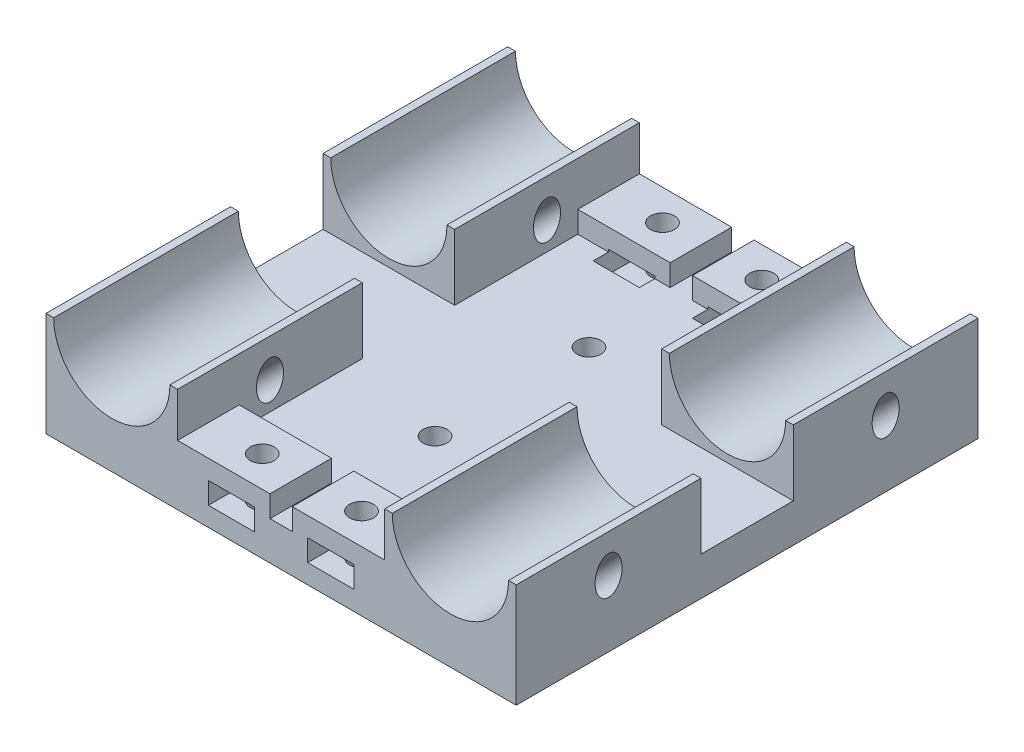
from build123d import *

# Parameters (mm, degrees)
SKETCH1_W               = 61.1
SKETCH1_H               = 60
BOSS_EXTRUDE1_DEPTH     = 5
BOSS_EXTRUDE2_DEPTH     = 24
MIRROR2_COPY_1_DEPTH    = 24
CUT_EXTRUDE1_START      = -47.739758236
SKETCH3_R               = 1.75
CUT_EXTRUDE1_DEPTH      = 54.785521216
MIRROR4_START           = -47.739758236
MIRROR4_COPY_1_SKETCH_R = 1.75
MIRROR4_COPY_1_DEPTH    = 54.785521216
MIRROR5_START           = -47.739758236
MIRROR5_COPY_1_SKETCH_R = 1.75
MIRROR5_COPY_1_DEPTH    = 54.785521216
MIRROR5_COPY_2_SKETCH_R = 1.75
MIRROR5_COPY_2_DEPTH    = 54.785521216
MIRROR5_COPY_3_SKETCH_R = 1.75
MIRROR5_COPY_3_DEPTH    = 54.785521216
SKETCH9_W               = 6
SKETCH9_H               = 2.5
BOSS_EXTRUDE4_DEPTH     = 8
SKETCH9_3_W             = 6
SKETCH9_3_H             = 2.5
CUT_EXTRUDE7_DEPTH      = 10
MIRROR7_COPY_1_SKETCH_W = 6
MIRROR7_COPY_1_SKETCH_H = 2.5
MIRROR7_COPY_1_DEPTH    = 8
MIRROR7_COPY_2_SKETCH_W = 6
MIRROR7_COPY_2_SKETCH_H = 2.5
MIRROR7_COPY_2_DEPTH    = 10
SKETCH10_R              = 1.55
CUT_EXTRUDE8_DEPTH      = 10
SKETCH11_R              = 1.55
CUT_EXTRUDE9_DEPTH      = 10


with BuildPart() as part:
    # Sketch1 → Boss-Extrude1 (new body)
    with BuildSketch(Plane(origin=(0, 0, 0), x_dir=(1, 0, 0), z_dir=(0, 1, 0))):
        Rectangle(SKETCH1_W, SKETCH1_H)
    extrude(amount=BOSS_EXTRUDE1_DEPTH)

    # Sketch2 → Boss-Extrude2 (add)
    with BuildSketch(Plane.XY.offset(30)):
        with BuildLine():
            Line((-30.55, 13.55), (-30.55, 5))
            Line((-30.55, 5), (-13.45, 5))
            Line((-13.45, 5), (-13.45, 13.55))
            Line((-13.45, 13.55), (-14.45, 13.55))
            ThreePointArc((-14.45, 13.55), (-22, 6), (-29.55, 13.55))
            Line((-29.55, 13.55), (-30.55, 13.55))
        make_face()
    boss_extrude2 = extrude(amount=-BOSS_EXTRUDE2_DEPTH)

    # Mirror1: Boss-Extrude2 across plane
    add(boss_extrude2.mirror(Plane.XY))

    # Mirror2: Boss-Extrude2 across plane
    add(boss_extrude2.mirror(Plane(origin=(0, 0, 0), x_dir=(0, 0, 1), z_dir=(1, 0, 0))))

    # Mirror2 copy 1 sketch → Mirror2 copy 1 (add)
    with BuildSketch(Plane(origin=(0, 0, -30), x_dir=(-1, 0, 0), z_dir=(0, 0, -1))):
        with BuildLine():
            Line((-30.55, 13.55), (-30.55, 5))
            Line((-30.55, 5), (-13.45, 5))
            Line((-13.45, 5), (-13.45, 13.55))
            Line((-13.45, 13.55), (-14.45, 13.55))
            ThreePointArc((-14.45, 13.55), (-22, 6), (-29.55, 13.55))
            Line((-29.55, 13.55), (-30.55, 13.55))
        make_face()
    extrude(amount=-MIRROR2_COPY_1_DEPTH)

    # Sketch3 → Cut-Extrude1 (cut)
    with BuildSketch(Plane(origin=(-17.775, 17.775, 0), x_dir=(0.707106781, 0.707106781, 0), z_dir=(-0.707106781, 0.707106781, 0)).offset(CUT_EXTRUDE1_START)):
        with Locations(Location((-15.52081528, -18, 0), (0, 0, 180))):  # turned: the seam where the file's is
            Circle(SKETCH3_R)
    cut_extrude1 = extrude(amount=CUT_EXTRUDE1_DEPTH, mode=Mode.SUBTRACT)

    # Mirror3: Cut-Extrude1 across plane
    add(cut_extrude1.mirror(Plane.ZY.offset(22)), mode=Mode.SUBTRACT)

    # Mirror4: Cut-Extrude1 across plane
    add(cut_extrude1.mirror(Plane.XY), mode=Mode.SUBTRACT)

    # Mirror4 copy 1 sketch → Mirror4 copy 1 (cut)
    with BuildSketch(Plane(origin=(-26.225, 17.775, 0), x_dir=(-0.707106781, 0.707106781, 0), z_dir=(0.707106781, 0.707106781, 0)).offset(MIRROR4_START)):
        with Locations(Location((-15.52081528, -18, 0), (0, 0, 180))):  # turned: the seam where the file's is
            Circle(MIRROR4_COPY_1_SKETCH_R)
    extrude(amount=MIRROR4_COPY_1_DEPTH, mode=Mode.SUBTRACT)

    # Mirror5: Cut-Extrude1 across plane
    add(cut_extrude1.mirror(Plane(origin=(0, 0, 0), x_dir=(0, 0, 1), z_dir=(1, 0, 0))), mode=Mode.SUBTRACT)

    # Mirror5 copy 1 sketch → Mirror5 copy 1 (cut)
    with BuildSketch(Plane(origin=(17.775, 17.775, 0), x_dir=(-0.707106781, 0.707106781, 0), z_dir=(0.707106781, 0.707106781, 0)).offset(MIRROR5_START)):
        with Locations(Location((-15.52081528, -18, 0), (0, 0, 180))):  # turned: the seam where the file's is
            Circle(MIRROR5_COPY_1_SKETCH_R)
    extrude(amount=MIRROR5_COPY_1_DEPTH, mode=Mode.SUBTRACT)

    # Mirror5 copy 2 sketch → Mirror5 copy 2 (cut)
    with BuildSketch(Plane(origin=(26.225, 17.775, 0), x_dir=(0.707106781, 0.707106781, 0), z_dir=(-0.707106781, 0.707106781, 0)).offset(MIRROR5_START)):
        with Locations((-15.52081528, 18)):
            Circle(MIRROR5_COPY_2_SKETCH_R)
    extrude(amount=MIRROR5_COPY_2_DEPTH, mode=Mode.SUBTRACT)

    # Mirror5 copy 3 sketch → Mirror5 copy 3 (cut)
    with BuildSketch(Plane(origin=(26.225, 17.775, 0), x_dir=(0.707106781, 0.707106781, 0), z_dir=(-0.707106781, 0.707106781, 0)).offset(MIRROR5_START)):
        with Locations(Location((-15.52081528, -18, 0), (0, 0, 180))):  # turned: the seam where the file's is
            Circle(MIRROR5_COPY_3_SKETCH_R)
    extrude(amount=MIRROR5_COPY_3_DEPTH, mode=Mode.SUBTRACT)

    # Sketch9 → Boss-Extrude4 (add)
    with BuildSketch(Plane.XY.offset(30)):
        Polygon((-13.45, 7.8), (-13.45, 5), (-9.45, 5), (-9.45, 5.3), (-3.45, 5.3), (-3.45, 5), (-1.45, 5), (-1.45, 7.8), align=None)
        with Locations((-6.45, 3.75)):
            Rectangle(SKETCH9_W, SKETCH9_H)
    boss_extrude4 = extrude(amount=-BOSS_EXTRUDE4_DEPTH)

    # Sketch9_3 → Cut-Extrude7 (cut)
    with BuildSketch(Plane.XY.offset(30)):
        with Locations((-6.45, 3.75)):
            Rectangle(SKETCH9_3_W, SKETCH9_3_H)
    cut_extrude7 = extrude(amount=-CUT_EXTRUDE7_DEPTH, mode=Mode.SUBTRACT)

    # Mirror6: Boss-Extrude4, Cut-Extrude7 across plane
    add(boss_extrude4.mirror(Plane.XY))
    add(cut_extrude7.mirror(Plane.XY), mode=Mode.SUBTRACT)

    # Mirror7: Boss-Extrude4, Cut-Extrude7 across plane
    add(boss_extrude4.mirror(Plane(origin=(0, 0, 0), x_dir=(0, 0, 1), z_dir=(1, 0, 0))))
    add(cut_extrude7.mirror(Plane(origin=(0, 0, 0), x_dir=(0, 0, 1), z_dir=(1, 0, 0))), mode=Mode.SUBTRACT)

    # Mirror7 copy 1 sketch → Mirror7 copy 1 (add)
    with BuildSketch(Plane(origin=(0, 0, -30), x_dir=(-1, 0, 0), z_dir=(0, 0, -1))):
        Polygon((-13.45, 7.8), (-13.45, 5), (-9.45, 5), (-9.45, 5.3), (-3.45, 5.3), (-3.45, 5), (-1.45, 5), (-1.45, 7.8), align=None)
        with Locations((-6.45, 3.75)):
            Rectangle(MIRROR7_COPY_1_SKETCH_W, MIRROR7_COPY_1_SKETCH_H)
    extrude(amount=-MIRROR7_COPY_1_DEPTH)

    # Mirror7 copy 2 sketch → Mirror7 copy 2 (cut)
    with BuildSketch(Plane(origin=(0, 0, -30), x_dir=(-1, 0, 0), z_dir=(0, 0, -1))):
        with Locations((-6.45, 3.75)):
            Rectangle(MIRROR7_COPY_2_SKETCH_W, MIRROR7_COPY_2_SKETCH_H)
    extrude(amount=-MIRROR7_COPY_2_DEPTH, mode=Mode.SUBTRACT)

    # Sketch10 → Cut-Extrude8 (cut)
    with BuildSketch(Plane(origin=(0, 7.8, 0), x_dir=(1, 0, 0), z_dir=(0, 1, 0))):
        with Locations(Location((-6.45, 26, 0), (0, 0, 270))):  # turned: the seam where the file's is
            Circle(SKETCH10_R)
        with Locations(Location((6.45, 26, 0), (0, 0, 270))):  # turned: the seam where the file's is
            Circle(SKETCH10_R)
        with Locations(Location((6.45, -26, 0), (0, 0, 270))):  # turned: the seam where the file's is
            Circle(SKETCH10_R)
        with Locations(Location((-6.45, -26, 0), (0, 0, 270))):  # turned: the seam where the file's is
            Circle(SKETCH10_R)
    extrude(amount=-CUT_EXTRUDE8_DEPTH, mode=Mode.SUBTRACT)

    # Sketch11 → Cut-Extrude9 (cut)
    with BuildSketch(Plane.XZ):
        with Locations(Location((0, 10, 0), (0, 0, 270))):  # turned: the seam where the file's is
            Circle(SKETCH11_R)
        with Locations(Location((0, -10, 0), (0, 0, 270))):  # turned: the seam where the file's is
            Circle(SKETCH11_R)
    extrude(amount=-CUT_EXTRUDE9_DEPTH, mode=Mode.SUBTRACT)


solid = part.part
